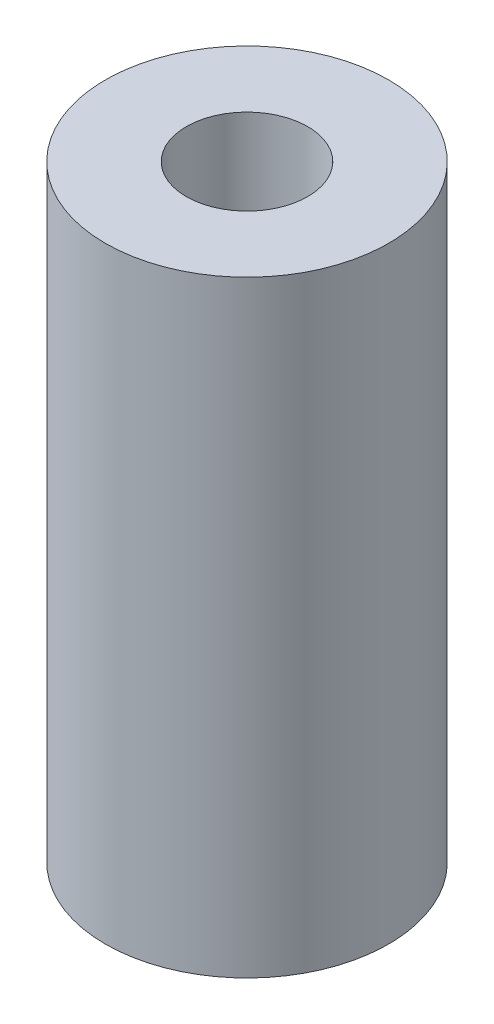
from build123d import *

# Parameters (mm, degrees)
SKETCH_1_R      = 3.5
SKETCH_1_R_2    = 1.5
EXTRUDE_1_DEPTH = 15


with BuildPart() as part:
    # 草图1 → 凸台-拉伸1 (new body)
    with BuildSketch(Plane(origin=(0, 0, 0), x_dir=(1, 0, 0), z_dir=(0, 1, 0))):
        Circle(SKETCH_1_R)
        Circle(SKETCH_1_R_2, mode=Mode.SUBTRACT)
    extrude(amount=EXTRUDE_1_DEPTH)


solid = part.part
